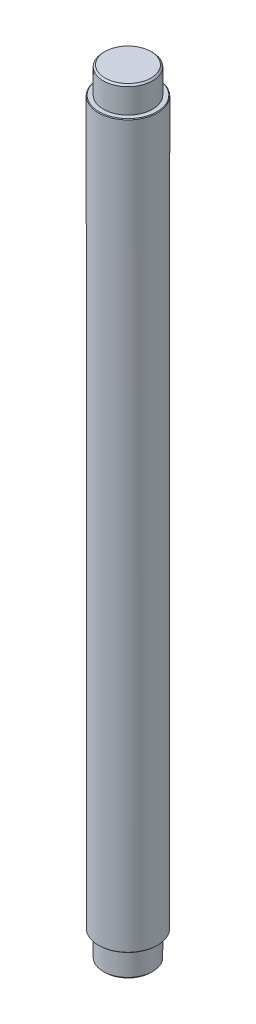
from build123d import *

# Parameters (mm, degrees)
CHAMFER_1_SIZE                 = 0.5
HOLE_WIZARD_6_0_6_4_AT_2_COUNT = 2
HOLE_WIZARD_6_0_6_4_AT_2_PITCH = 65
HOLE_WIZARD_6_0_6_4_AT_3_COUNT = 2
HOLE_WIZARD_6_0_6_4_AT_3_PITCH = 113
HOLE_WIZARD_6_0_6_4_AT_4_COUNT = 2
HOLE_WIZARD_6_0_6_4_AT_4_PITCH = 48
PATTERN_CIRCULAR_1_COUNT       = 4
CHAMFER_2_SIZE                 = 0.2


with BuildPart() as part:
    # 草图1 → 旋转1 (revolve)
    with BuildSketch(Plane.XY):
        Polygon((0, 118), (0, -118), (-7.5, -118), (-7.5, -110), (-9, -110), (-9, 110), (-7.5, 110), (-7.5, 118), align=None)
    revolve(axis=Axis((0, 118, 0), (0, -1, 0)))

    # 倒角1
    chamfer_1_edges = [part.edges().sort_by_distance(p)[0] for p in [
        (7.5, 118, 0),
        (7.5, -118, 0),
    ]]
    chamfer(chamfer_1_edges, length=CHAMFER_1_SIZE)

    # 草图3 → Ø6.0 (6) 直径孔4 (revolve, cut)
    with BuildSketch(Plane(origin=(0, -32.5, -9), x_dir=(0, 1, 0), z_dir=(1, 0, 0))):
        Polygon((0, 0), (0, 3.802581857), (3, 2), (3, 0), align=None)
    hole_wizard_6_0_6_4 = revolve(axis=Axis((0, -32.5, -15.35), (0, 0, 1)), mode=Mode.SUBTRACT)

    # Ø6.0 (6) 直径孔4 at 2: Ø6.0 (6) 直径孔4 ×2
    with Locations(*[(0, i * HOLE_WIZARD_6_0_6_4_AT_2_PITCH, 0) for i in range(1, HOLE_WIZARD_6_0_6_4_AT_2_COUNT)]):
        add(hole_wizard_6_0_6_4, mode=Mode.SUBTRACT)

    # Ø6.0 (6) 直径孔4 at 3: Ø6.0 (6) 直径孔4 ×2
    with Locations(*[(0, i * HOLE_WIZARD_6_0_6_4_AT_3_PITCH, 0) for i in range(1, HOLE_WIZARD_6_0_6_4_AT_3_COUNT)]):
        add(hole_wizard_6_0_6_4, mode=Mode.SUBTRACT)

    # Ø6.0 (6) 直径孔4 at 4: Ø6.0 (6) 直径孔4 ×2
    with Locations(*[(0, -i * HOLE_WIZARD_6_0_6_4_AT_4_PITCH, 0) for i in range(1, HOLE_WIZARD_6_0_6_4_AT_4_COUNT)]):
        add(hole_wizard_6_0_6_4, mode=Mode.SUBTRACT)

    # 阵列(圆周)1: Ø6.0 (6) 直径孔4 ×4 about axis, 2 skipped
    pattern_circular_1_axis = Axis((0, 118, 0), (0, 1, 0))
    add([hole_wizard_6_0_6_4.rotate(pattern_circular_1_axis, i * 360 / PATTERN_CIRCULAR_1_COUNT) for i in range(1, PATTERN_CIRCULAR_1_COUNT) if i not in (2, 3)], mode=Mode.SUBTRACT)

    # 阵列(圆周)1 copy 1 sketch → 阵列(圆周)1 copy 1 (revolve, cut)
    with BuildSketch(Plane(origin=(-9, 32.5, 0), x_dir=(0, 1, 0), z_dir=(0, 0, -1))):
        Polygon((0, 0), (0, 3.802581857), (3, 2), (3, 0), align=None)
    revolve(axis=Axis((-15.35, 32.5, 0), (1, 0, 0)), mode=Mode.SUBTRACT)

    # 阵列(圆周)1 copy 2 sketch → 阵列(圆周)1 copy 2 (revolve, cut)
    with BuildSketch(Plane(origin=(-9, 80.5, 0), x_dir=(0, 1, 0), z_dir=(0, 0, -1))):
        Polygon((0, 0), (0, 3.802581857), (3, 2), (3, 0), align=None)
    revolve(axis=Axis((-15.35, 80.5, 0), (1, 0, 0)), mode=Mode.SUBTRACT)

    # 阵列(圆周)1 copy 3 sketch → 阵列(圆周)1 copy 3 (revolve, cut)
    with BuildSketch(Plane(origin=(-9, -80.5, 0), x_dir=(0, 1, 0), z_dir=(0, 0, -1))):
        Polygon((0, 0), (0, 3.802581857), (3, 2), (3, 0), align=None)
    revolve(axis=Axis((-15.35, -80.5, 0), (1, 0, 0)), mode=Mode.SUBTRACT)

    # 倒角2
    chamfer_2_edges = [part.edges().sort_by_distance(p)[0] for p in [
        (9, 110, 0),
        (9, -110, 0),
    ]]
    chamfer(chamfer_2_edges, length=CHAMFER_2_SIZE)


solid = part.part
